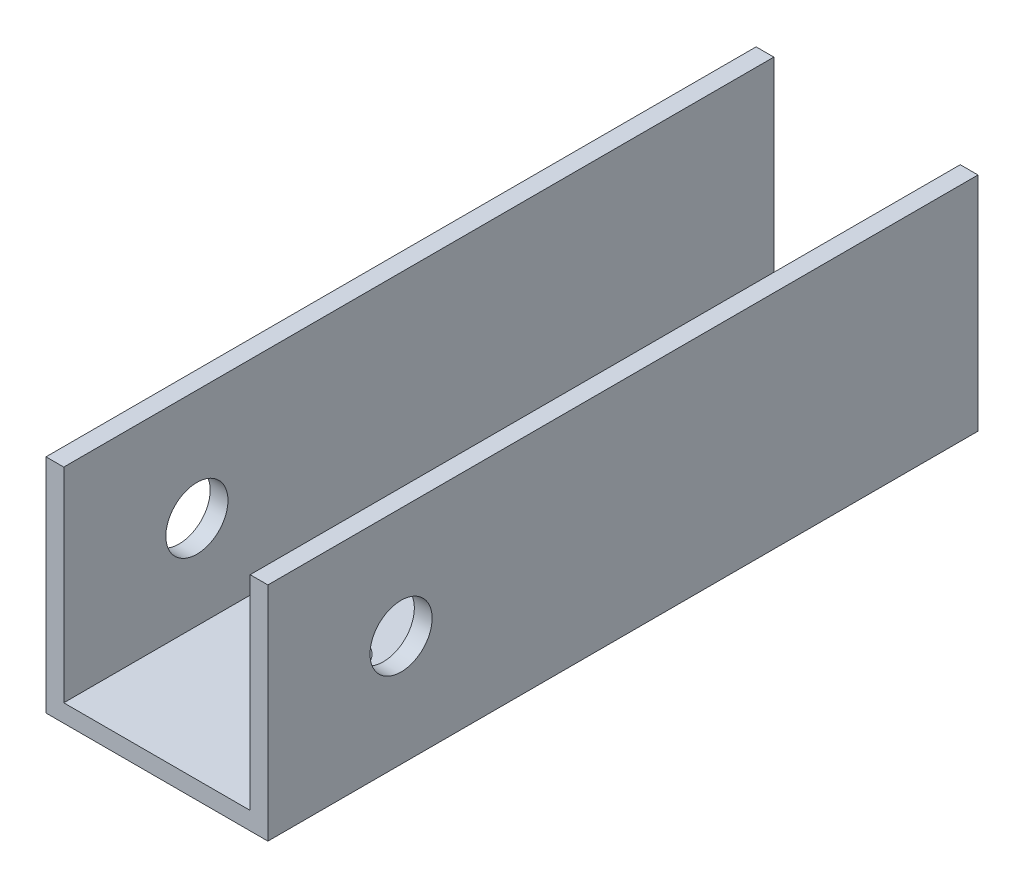
from build123d import *

# Parameters (mm, degrees)
BOSS_EXTRUDE1_DEPTH = 80
SKETCH3_R           = 3.5
CUT_EXTRUDE1_DEPTH  = 25
CUT_EXTRUDE2_REACH  = 27
SKETCH4_R           = 3


with BuildPart() as part:
    # Sketch2 → Boss-Extrude1 (new body)
    with BuildSketch(Plane.XY):
        Polygon((23, 25), (25, 25), (25, 0), (0, 0), (0, 25), (2, 25), (2, 2), (23, 2), align=None)
    extrude(amount=BOSS_EXTRUDE1_DEPTH)

    # Sketch3 → Cut-Extrude1 (cut)
    with BuildSketch(Plane(origin=(25, 0, 0), x_dir=(0, 0, -1), z_dir=(1, 0, 0))):
        with Locations((-65, 12.5)):
            Circle(SKETCH3_R)
    extrude(amount=-CUT_EXTRUDE1_DEPTH, mode=Mode.SUBTRACT)

    # Sketch4 → Cut-Extrude2 (cut, up to next)
    with BuildSketch(Plane.XZ, mode=Mode.PRIVATE) as cut_extrude2_sk1:
        with Locations((12.5, 60)):
            Circle(SKETCH4_R)
    cut_extrude2_tool1 = extrude(cut_extrude2_sk1.sketch, amount=-CUT_EXTRUDE2_REACH, mode=Mode.PRIVATE) & part.part
    add(cut_extrude2_tool1.solids().sort_by_distance((12.5, 0, 60))[0], mode=Mode.SUBTRACT)
    # Sketch4 → Cut-Extrude2 (cut, up to next)
    with BuildSketch(Plane.XZ, mode=Mode.PRIVATE) as cut_extrude2_sk2:
        with Locations((12.5, 20)):
            Circle(SKETCH4_R)
    cut_extrude2_tool2 = extrude(cut_extrude2_sk2.sketch, amount=-CUT_EXTRUDE2_REACH, mode=Mode.PRIVATE) & part.part
    add(cut_extrude2_tool2.solids().sort_by_distance((12.5, 0, 20))[0], mode=Mode.SUBTRACT)


solid = part.part
